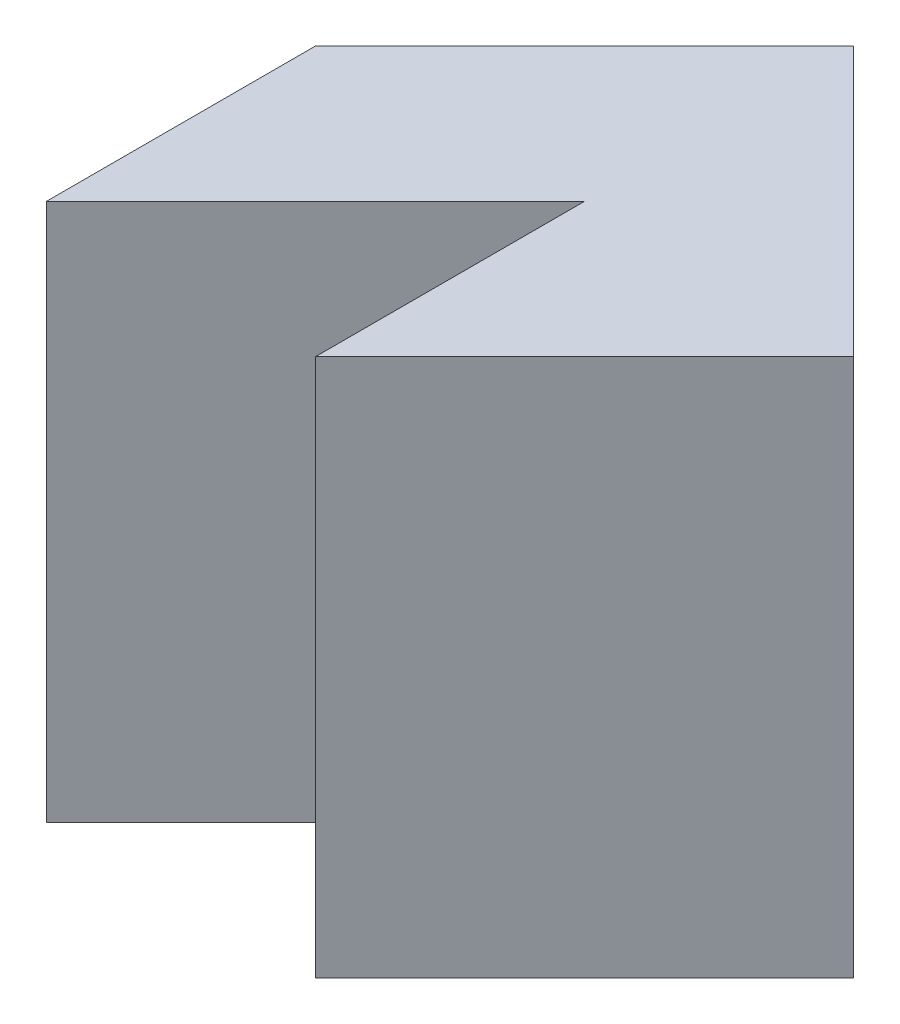
from build123d import *

# Parameters (mm, degrees)
BOSS_EXTRUDE2_DEPTH = 4


with BuildPart() as part:
    # Sketch2 → Boss-Extrude2 (new body)
    with BuildSketch(Plane(origin=(0, 0, 0), x_dir=(1, 0, 0), z_dir=(0, 1, 0))):
        Polygon((0, 0), (0, 2), (-2, 0), (-2, 2), (0, 4), (2, 2), align=None)
    extrude(amount=BOSS_EXTRUDE2_DEPTH)


solid = part.part
